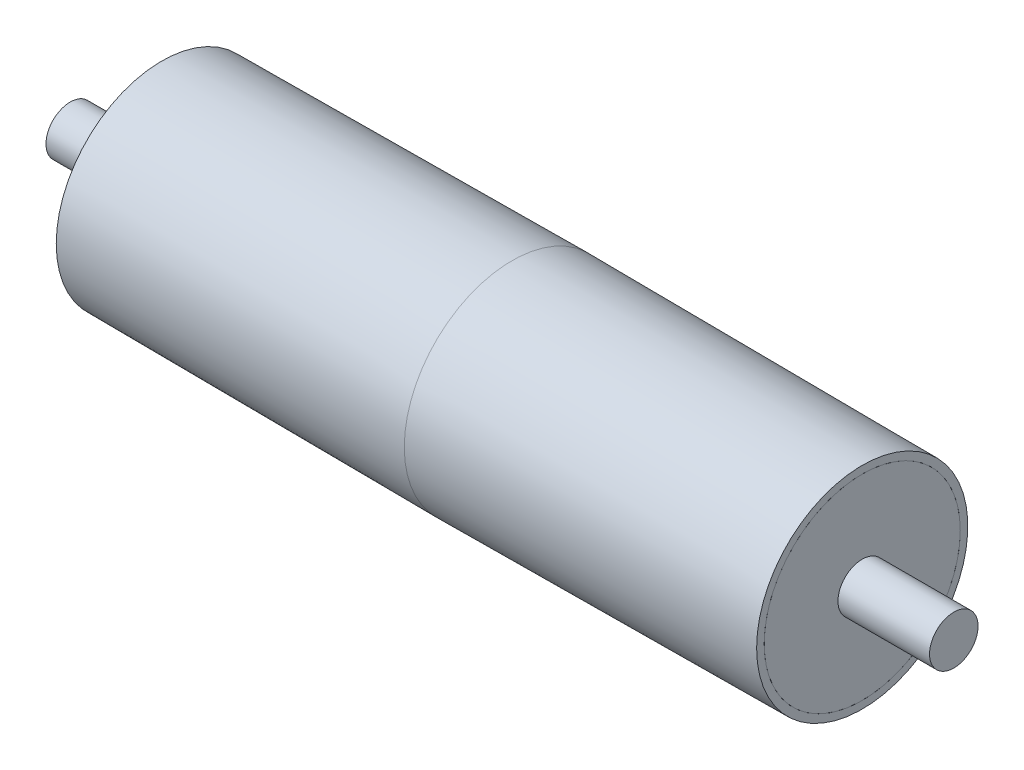
from build123d import *

# Parameters (mm, degrees)
SHELL1_T            = -7
SKETCH2_R           = 90.999867457
BOSS_EXTRUDE1_DEPTH = 10
SKETCH3_R           = 22.5
CUT_EXTRUDE1_DEPTH  = 735
SKETCH4_R           = 22.5
BOSS_EXTRUDE2_DEPTH = 410


with BuildPart() as part:
    # Sketch1 → Revolve1 (revolve)
    with BuildSketch(Plane.XY, mode=Mode.PRIVATE) as revolve1_sk:
        Polygon((-325, 98), (0, 100), (325, 98), (325, 0), (-325, 0), align=None)
    revolve(revolve1_sk.sketch.rotate(Axis((-325, 0, 0), (1, 0, 0)), 90), axis=Axis((-325, 0, 0), (1, 0, 0)))

    # Shell1
    shell1_openings = [part.faces().sort_by_distance(p)[0] for p in [
        (325, 0, 0),
        (-325, 0, 0),
    ]]
    offset(amount=SHELL1_T, openings=shell1_openings)


with BuildPart() as body_2:
    # Sketch2 → Boss-Extrude1 (new body)
    with BuildSketch(Plane(origin=(325, 0, 0), x_dir=(0, 0, -1), z_dir=(1, 0, 0))):
        Circle(SKETCH2_R)
    extrude(amount=-BOSS_EXTRUDE1_DEPTH)


with BuildPart() as body_3:
    # Mirror2: mirrored copy
    add(body_2.part.mirror(Plane(origin=(0, 0, 0), x_dir=(0, 0, 1), z_dir=(1, 0, 0))))


with BuildPart() as cut_extrude1_tool:
    # Sketch3 → Cut-Extrude1 (new body)
    with BuildSketch(Plane(origin=(325, 0, 0), x_dir=(0, 0, -1), z_dir=(1, 0, 0))):
        with Locations(Location((0, 0, 0), (0, 0, 180))):
            Circle(SKETCH3_R)
    extrude(amount=-CUT_EXTRUDE1_DEPTH)


with BuildPart() as body_2_1:
    add(body_2.part)

    # Cut-Extrude1: cut by cut_extrude1_tool
    add(cut_extrude1_tool.part, mode=Mode.SUBTRACT)


with BuildPart() as body_3_1:
    add(body_3.part)

    # Cut-Extrude1: cut by cut_extrude1_tool
    add(cut_extrude1_tool.part, mode=Mode.SUBTRACT)


with BuildPart() as body_4:
    # Sketch4 → Boss-Extrude2 (new, symmetric)
    with BuildSketch(Plane(origin=(0, 0, 0), x_dir=(0, 0, -1), z_dir=(1, 0, 0))):
        with Locations(Location((0, 0, 0), (0, 0, 180))):
            Circle(SKETCH4_R)
    extrude(amount=BOSS_EXTRUDE2_DEPTH, both=True)


solid = Compound([part.part, body_2_1.part, body_3_1.part, body_4.part])
